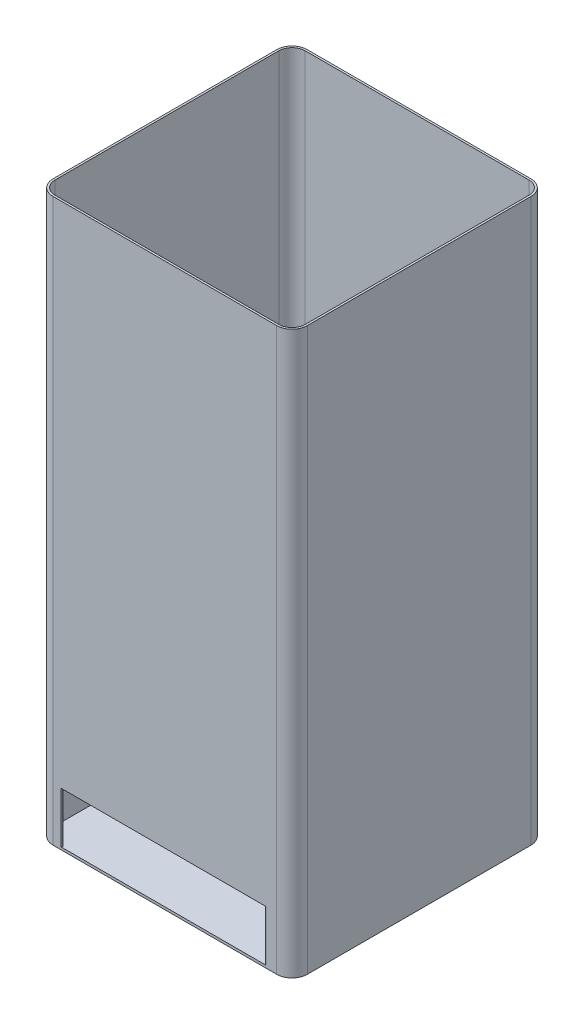
from build123d import *

# Parameters (mm, degrees)
EXTRUDE_1_DEPTH = 5
EXTRUDE_2_DEPTH = 100
EXTRUDE_3_DEPTH = 1000


with BuildPart() as part:
    # 草图1 → 凸台-拉伸1 (new body)
    with BuildSketch(Plane(origin=(0, 0, 0), x_dir=(1, 0, 0), z_dir=(0, 1, 0))):
        with BuildLine():
            Line((220, 250), (-220, 250))
            ThreePointArc((-220, 250), (-241.213203436, 241.213203436), (-250, 220))
            Line((-250, 220), (-250, -220))
            ThreePointArc((-250, -220), (-241.213203436, -241.213203436), (-220, -250))
            Line((-220, -250), (220, -250))
            ThreePointArc((220, -250), (241.213203436, -241.213203436), (250, -220))
            Line((250, -220), (250, 220))
            ThreePointArc((250, 220), (241.213203436, 241.213203436), (220, 250))
        make_face()
    extrude(amount=EXTRUDE_1_DEPTH)

    # 草图2 → 凸台-拉伸2 (add)
    with BuildSketch(Plane(origin=(0, 5, 0), x_dir=(1, 0, 0), z_dir=(0, 1, 0))):
        with BuildLine():
            Line((-220, -246), (-204.515980858, -246))
            ThreePointArc((-204.515980858, -246), (-203.455320686, -246.439339828), (-203.015980858, -247.5))
            Line((-203.015980858, -247.5), (-203.015980858, -248.5))
            ThreePointArc((-203.015980858, -248.5), (-203.455320686, -249.560660172), (-204.515980858, -250))
            Line((-204.515980858, -250), (-220, -250))
            ThreePointArc((-220, -250), (-241.213203436, -241.213203436), (-250, -220))
            Line((-250, -220), (-250, 220))
            ThreePointArc((-250, 220), (-241.213203436, 241.213203436), (-220, 250))
            Line((-220, 250), (220, 250))
            ThreePointArc((220, 250), (241.213203436, 241.213203436), (250, 220))
            Line((250, 220), (250, -220))
            ThreePointArc((250, -220), (241.213203436, -241.213203436), (220, -250))
            Line((220, -250), (198.484019142, -250))
            ThreePointArc((198.484019142, -250), (197.42335897, -249.560660172), (196.984019142, -248.5))
            Line((196.984019142, -248.5), (196.984019142, -247.5))
            ThreePointArc((196.984019142, -247.5), (197.42335897, -246.439339828), (198.484019142, -246))
            Line((198.484019142, -246), (220, -246))
            ThreePointArc((220, -246), (238.384776311, -238.384776311), (246, -220))
            Line((246, -220), (246, 220))
            ThreePointArc((246, 220), (238.384776311, 238.384776311), (220, 246))
            Line((220, 246), (-220, 246))
            ThreePointArc((-220, 246), (-238.384776311, 238.384776311), (-246, 220))
            Line((-246, 220), (-246, -220))
            ThreePointArc((-246, -220), (-238.384776311, -238.384776311), (-220, -246))
        make_face()
    extrude(amount=EXTRUDE_2_DEPTH)

    # 草图3 → 凸台-拉伸3 (add)
    with BuildSketch(Plane(origin=(0, 105, 0), x_dir=(1, 0, 0), z_dir=(0, 1, 0))):
        with BuildLine():
            Line((-204.515980858, -246), (-220, -246))
            ThreePointArc((-220, -246), (-238.384776311, -238.384776311), (-246, -220))
            Line((-246, -220), (-246, 220))
            ThreePointArc((-246, 220), (-238.384776311, 238.384776311), (-220, 246))
            Line((-220, 246), (220, 246))
            ThreePointArc((220, 246), (238.384776311, 238.384776311), (246, 220))
            Line((246, 220), (246, -220))
            ThreePointArc((246, -220), (238.384776311, -238.384776311), (220, -246))
            Line((220, -246), (198.484019142, -246))
            ThreePointArc((198.484019142, -246), (197.42335897, -246.439339828), (196.984019142, -247.5))
            Line((196.984019142, -247.5), (196.984019142, -248.5))
            ThreePointArc((196.984019142, -248.5), (197.42335897, -249.560660172), (198.484019142, -250))
            Line((198.484019142, -250), (220, -250))
            ThreePointArc((220, -250), (241.213203436, -241.213203436), (250, -220))
            Line((250, -220), (250, 220))
            ThreePointArc((250, 220), (241.213203436, 241.213203436), (220, 250))
            Line((220, 250), (-220, 250))
            ThreePointArc((-220, 250), (-241.213203436, 241.213203436), (-250, 220))
            Line((-250, 220), (-250, -220))
            ThreePointArc((-250, -220), (-241.213203436, -241.213203436), (-220, -250))
            Line((-220, -250), (-204.515980858, -250))
            ThreePointArc((-204.515980858, -250), (-203.455320686, -249.560660172), (-203.015980858, -248.5))
            Line((-203.015980858, -248.5), (-203.015980858, -247.5))
            ThreePointArc((-203.015980858, -247.5), (-203.455320686, -246.439339828), (-204.515980858, -246))
        make_face()
        with BuildLine():
            Line((-204.515980858, -250), (198.484019142, -250))
            ThreePointArc((198.484019142, -250), (197.42335897, -249.560660172), (196.984019142, -248.5))
            Line((196.984019142, -248.5), (196.984019142, -247.5))
            ThreePointArc((196.984019142, -247.5), (197.42335897, -246.439339828), (198.484019142, -246))
            Line((198.484019142, -246), (-204.515980858, -246))
            ThreePointArc((-204.515980858, -246), (-203.455320686, -246.439339828), (-203.015980858, -247.5))
            Line((-203.015980858, -247.5), (-203.015980858, -248.5))
            ThreePointArc((-203.015980858, -248.5), (-203.455320686, -249.560660172), (-204.515980858, -250))
        make_face()
    extrude(amount=EXTRUDE_3_DEPTH)


solid = part.part
